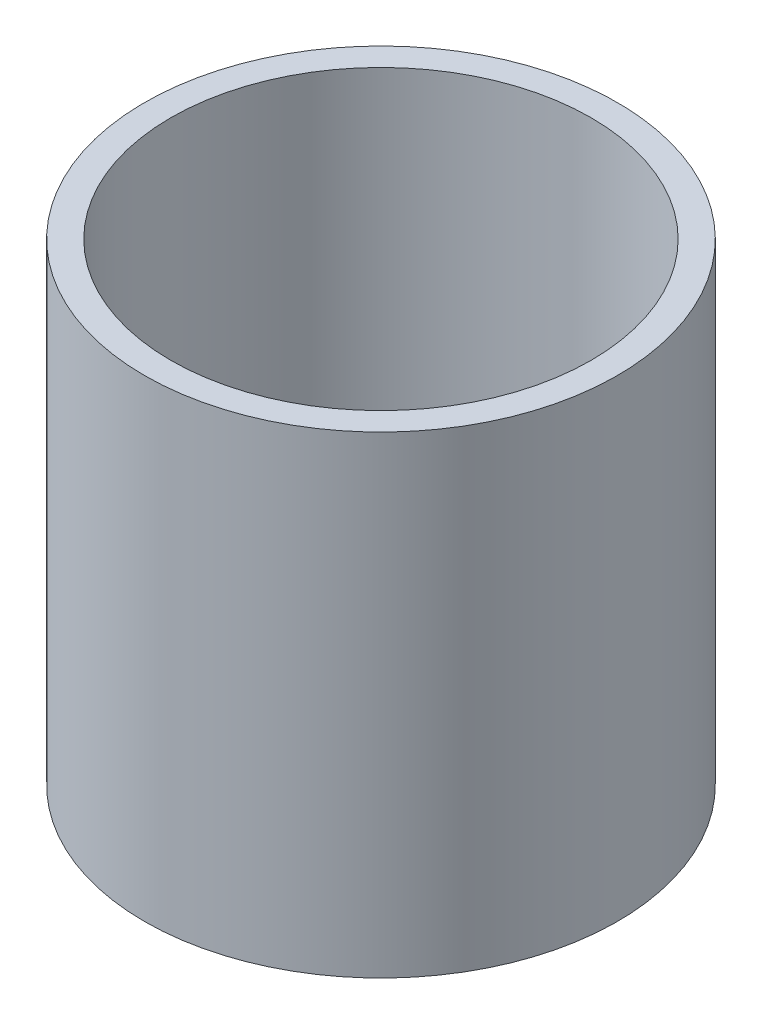
from build123d import *

# Parameters (mm, degrees)
SKETCH1_R           = 9
BOSS_EXTRUDE1_DEPTH = 18
SHELL1_T            = -1


with BuildPart() as part:
    # Sketch1 → Boss-Extrude1 (new body)
    with BuildSketch(Plane(origin=(0, 0, 0), x_dir=(1, 0, 0), z_dir=(0, 1, 0))):
        with Locations(Location((0, 0, 0), (0, 0, 270))):
            Circle(SKETCH1_R)
    extrude(amount=BOSS_EXTRUDE1_DEPTH)

    # Shell1
    shell1_openings = [part.faces().sort_by_distance(p)[0] for p in [
        (0, 18, 0),
    ]]
    offset(amount=SHELL1_T, openings=shell1_openings, kind=Kind.INTERSECTION)


solid = part.part
